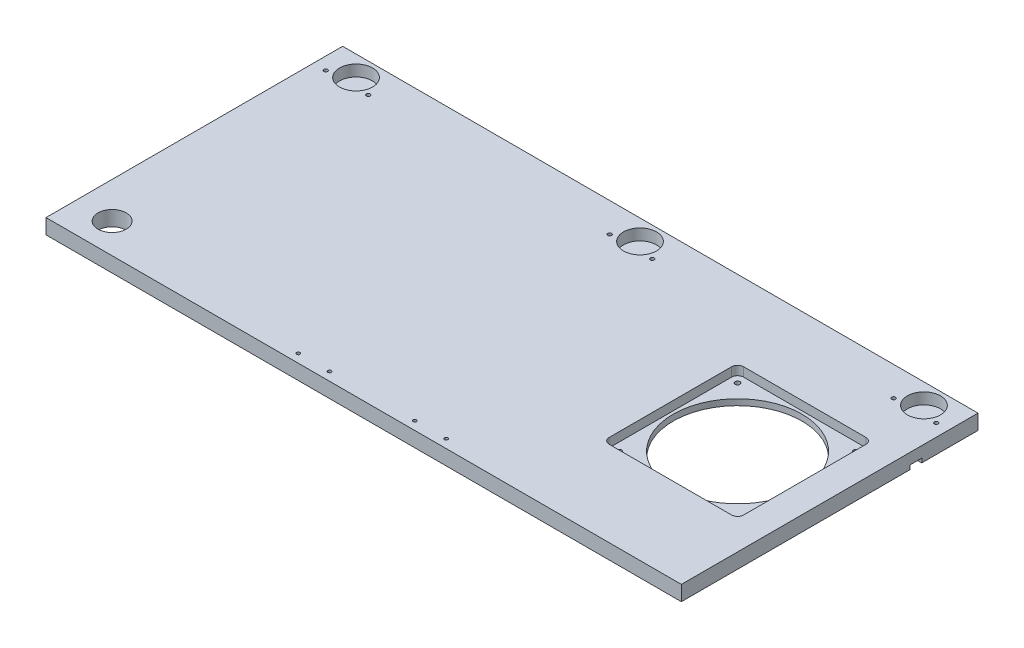
from build123d import *

# Parameters (mm, degrees)
SKETCH1_W               = 671.2712
SKETCH1_H               = 313.4106
BOSS_EXTRUDE1_DEPTH     = 15.875
SKETCH4_R               = 14.9225
CUT_EXTRUDE2_DEPTH      = 1
CUT_EXTRUDE2_DEPTH_BACK = 16.875
SKETCH5_R               = 17.4625
SKETCH5_R_2             = 2
CUT_EXTRUDE3_DEPTH      = 11.90625
SKETCH6_R               = 1.8
CUT_EXTRUDE4_DEPTH      = 2.54
SKETCH7_R               = 68
SKETCH7_R_2             = 2.54
CUT_EXTRUDE5_DEPTH      = 1
CUT_EXTRUDE5_DEPTH_BACK = 16.875
CUT_EXTRUDE6_DEPTH      = 9.525
SKETCH9_W               = 671.2712
SKETCH9_H               = 12.5
CUT_EXTRUDE7_DEPTH      = 4.35


with BuildPart() as part:
    # Sketch1 → Boss-Extrude1 (new body)
    with BuildSketch(Plane(origin=(0, 0, 0), x_dir=(1, 0, 0), z_dir=(0, 1, 0))):
        Rectangle(SKETCH1_W, SKETCH1_H)
    extrude(amount=BOSS_EXTRUDE1_DEPTH)

    # Sketch4 → Cut-Extrude2 (cut, two sides)
    with BuildSketch(Plane(origin=(0, 15.875, 0), x_dir=(1, 0, 0), z_dir=(0, 1, 0))) as cut_extrude2_sk:
        with Locations((-297.5356, -124.9553)):
            Circle(SKETCH4_R)
    extrude(amount=CUT_EXTRUDE2_DEPTH, mode=Mode.SUBTRACT)
    extrude(cut_extrude2_sk.sketch, amount=-CUT_EXTRUDE2_DEPTH_BACK, mode=Mode.SUBTRACT)

    # Sketch5 → Cut-Extrude3 (cut)
    with BuildSketch(Plane(origin=(0, 15.875, 0), x_dir=(1, 0, 0), z_dir=(0, 1, 0))):
        with Locations((0, 135.2428)):
            Circle(SKETCH5_R)
        with Locations((22.5, 125.7428)):
            Circle(SKETCH5_R_2)
        with Locations((-22.5, 125.7428)):
            Circle(SKETCH5_R_2)
        with Locations((-300, 135.2428)):
            Circle(SKETCH5_R)
        with Locations((-277.5, 125.7428)):
            Circle(SKETCH5_R_2)
        with Locations((-322.5, 125.7428)):
            Circle(SKETCH5_R_2)
        with Locations((322.5, 125.7428)):
            Circle(SKETCH5_R_2)
        with Locations((277.5, 125.7428)):
            Circle(SKETCH5_R_2)
        with Locations((300, 135.2428)):
            Circle(SKETCH5_R)
    extrude(amount=-CUT_EXTRUDE3_DEPTH, mode=Mode.SUBTRACT)

    # Sketch6 → Cut-Extrude4 (cut)
    with BuildSketch(Plane(origin=(0, 15.875, 0), x_dir=(1, 0, 0), z_dir=(0, 1, 0))):
        with Locations((78.0499912, -147.7053)):
            Circle(SKETCH6_R)
        with Locations((45.0499912, -147.7053)):
            Circle(SKETCH6_R)
        with Locations((-45.0499912, -147.7053)):
            Circle(SKETCH6_R)
        with Locations((-78.0499912, -147.7053)):
            Circle(SKETCH6_R)
    extrude(amount=-CUT_EXTRUDE4_DEPTH, mode=Mode.SUBTRACT)

    # Sketch7 → Cut-Extrude5 (cut, two sides)
    with BuildSketch(Plane(origin=(0, 15.875, 0), x_dir=(1, 0, 0), z_dir=(0, 1, 0))) as cut_extrude5_sk:
        with Locations((234.0356, 4.3053)):
            Circle(SKETCH7_R)
        with Locations((296.5356, -58.1947)):
            Circle(SKETCH7_R_2)
        with Locations((296.5356, 66.8053)):
            Circle(SKETCH7_R_2)
        with Locations((171.5356, 66.8053)):
            Circle(SKETCH7_R_2)
        with Locations((171.5356, -58.1947)):
            Circle(SKETCH7_R_2)
    extrude(amount=CUT_EXTRUDE5_DEPTH, mode=Mode.SUBTRACT)
    extrude(cut_extrude5_sk.sketch, amount=-CUT_EXTRUDE5_DEPTH_BACK, mode=Mode.SUBTRACT)

    # Sketch8 → Cut-Extrude6 (cut)
    with BuildSketch(Plane(origin=(0, 15.875, 0), x_dir=(1, 0, 0), z_dir=(0, 1, 0))):
        with BuildLine():
            Line((169.3856, -66.6947), (298.6856, -66.6947))
            ThreePointArc((298.6856, -66.6947), (303.175728061, -64.834828061), (305.0356, -60.3447))
            Line((305.0356, -60.3447), (305.0356, 68.9553))
            ThreePointArc((305.0356, 68.9553), (303.175728061, 73.445428061), (298.6856, 75.3053))
            Line((298.6856, 75.3053), (169.3856, 75.3053))
            ThreePointArc((169.3856, 75.3053), (164.895471939, 73.445428061), (163.0356, 68.9553))
            Line((163.0356, 68.9553), (163.0356, -60.3447))
            ThreePointArc((163.0356, -60.3447), (164.895471939, -64.834828061), (169.3856, -66.6947))
        make_face()
    extrude(amount=-CUT_EXTRUDE6_DEPTH, mode=Mode.SUBTRACT)

    # Sketch9 → Cut-Extrude7 (cut)
    with BuildSketch(Plane.XZ):
        with Locations((0, -91.0447)):
            Rectangle(SKETCH9_W, SKETCH9_H)
    extrude(amount=-CUT_EXTRUDE7_DEPTH, mode=Mode.SUBTRACT)


solid = part.part
